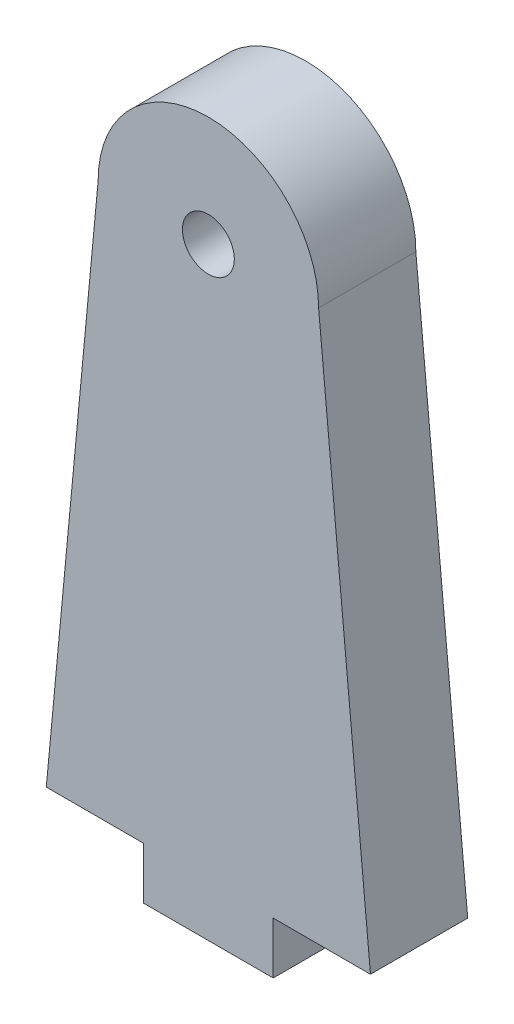
from build123d import *

# Parameters (mm, degrees)
SKETCH1_R                 = 7
BOSS_EXTRUDE1_DEPTH       = 15
F_8_0MM_DOWEL_HOLE1_D     = 8
F_8_0MM_DOWEL_HOLE1_DEPTH = 30
F_8_0MM_DOWEL_HOLE1_TIP   = 2.403442476
SKETCH3_R                 = 7
SKETCH3_R_2               = 4
BOSS_EXTRUDE2_DEPTH       = 15


with BuildPart() as part:
    # Sketch1 → Boss-Extrude1 (new body)
    with BuildSketch(Plane.XY):
        with BuildLine():
            Line((-10, 0), (10, 0))
            Line((10, 0), (10, 8))
            Line((10, 8), (25, 8))
            Line((25, 8), (17, 93))
            ThreePointArc((17, 93), (0, 110), (-17, 93))
            Line((-17, 93), (-25, 8))
            Line((-25, 8), (-10, 8))
            Line((-10, 8), (-10, 0))
        make_face()
        with Locations((0, 93)):
            Circle(SKETCH1_R, mode=Mode.SUBTRACT)
    extrude(amount=BOSS_EXTRUDE1_DEPTH)

    # Ø8.0mm Dowel Hole1
    with Locations(Plane(origin=(0, 0, 7.5), x_dir=(0, 0, -1), z_dir=(0, -1, 0))):
        with Locations((0, 0)):
            Hole(F_8_0MM_DOWEL_HOLE1_D / 2, depth=F_8_0MM_DOWEL_HOLE1_DEPTH)
            with Locations((0, 0, -(F_8_0MM_DOWEL_HOLE1_DEPTH + F_8_0MM_DOWEL_HOLE1_TIP / 2))):  # 118° drill point
                Cone(0, F_8_0MM_DOWEL_HOLE1_D / 2, F_8_0MM_DOWEL_HOLE1_TIP, mode=Mode.SUBTRACT)

    # Sketch3 → Boss-Extrude2 (add, through all)
    with BuildSketch(Plane.XY.offset(15)):
        with Locations((0, 93)):
            Circle(SKETCH3_R)
        with Locations((0, 93)):
            Circle(SKETCH3_R_2, mode=Mode.SUBTRACT)
    extrude(amount=-BOSS_EXTRUDE2_DEPTH)


solid = part.part
